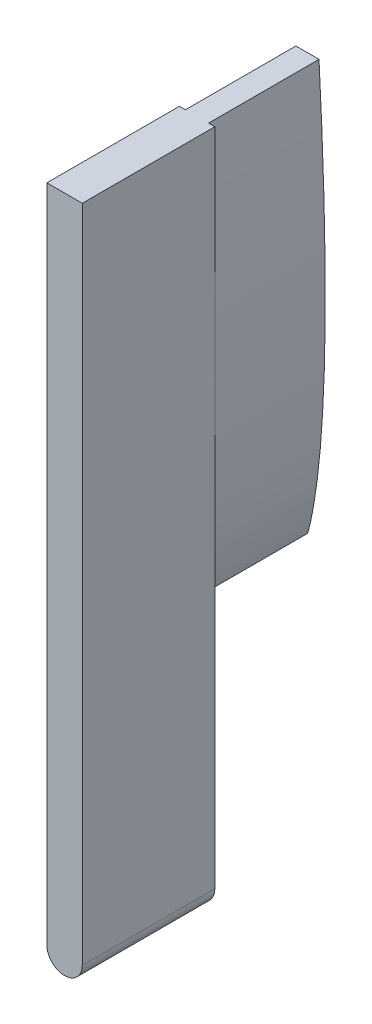
from build123d import *

# Parameters (mm, degrees)
BOSS_EXTRUDE1_DEPTH = 12
BOSS_EXTRUDE2_DEPTH = 10
SKETCH4_W           = 13.751659717
SKETCH4_H           = 46.366215506
CUT_EXTRUDE1_DEPTH  = 10
SKETCH5_W           = 8.283570047
SKETCH5_H           = 65.91855038
CUT_EXTRUDE2_DEPTH  = 12


with BuildPart() as part:
    # Sketch2 → Boss-Extrude1 (new body)
    with BuildSketch(Plane(origin=(0, 0, 24.631338753), x_dir=(-1, 0, 0), z_dir=(0, 0, -1))):
        with BuildLine():
            Line((1.823068058, 603), (1.823068058, 663))
            Line((1.823068058, 663), (-1.882857166, 663))
            Line((-1.882857166, 663), (-1.882857166, 603))
            ThreePointArc((-1.882857166, 603), (-0.029894554, 601.147037388), (1.823068058, 603))
        make_face()
    extrude(amount=-BOSS_EXTRUDE1_DEPTH)

    # Sketch3 → Boss-Extrude2 (add)
    with BuildSketch(Plane(origin=(0, 0, 24.631338753), x_dir=(-1, 0, 0), z_dir=(0, 0, -1))):
        with BuildLine():
            Line((1.264894076, 663), (-1.303734146, 663))
            add(Edge.make_bspline(
                [(-1.303734146, 663), (-1.370231135, 661.776635062), (-1.590250356, 657.449713113), (-1.807353062, 651.572171687), (-1.896585428, 645.372497792), (-1.86904968, 640.732879739), (-1.745534221, 636.874692995), (-1.562088565, 633.805492743), (-1.371788238, 631.514699269), (-1.110556109, 629.246267473), (-0.82006967, 627.376977333), (-0.524480825, 625.91989796), (-0.290142677, 624.999996337), (-0.11575841, 624.480032386), (-0.0414459, 624.290359908)],
                knots=[0.640306561, 0.640306561, 0.640306561, 0.640306561, 0.664641164, 0.726373771, 0.757240075, 0.788106379, 0.818972683, 0.834405835, 0.849838987, 0.865272139, 0.88070529, 0.888421866, 0.896138442, 0.901180622, 0.901180622, 0.901180622, 0.901180622], degree=3))
            add(Edge.make_bspline(
                [(-0.0414459, 624.290359908), (0.033082795, 624.479947544), (0.208059728, 624.999712352), (0.443446447, 625.919346223), (0.740696225, 627.376087666), (1.033313538, 629.245045426), (1.297131595, 631.513177934), (1.490043391, 633.803752969), (1.676987934, 636.872742091), (1.804901792, 640.730785516), (1.837726863, 645.370369162), (1.755562421, 651.570140757), (1.545143008, 657.448413886), (1.33002573, 661.776072077), (1.264894076, 663)],
                knots=[0.516530112, 0.516530112, 0.516530112, 0.516530112, 0.521572291, 0.529288867, 0.537005443, 0.552438595, 0.567871747, 0.583304899, 0.598738051, 0.629604354, 0.660470658, 0.691336962, 0.75306957, 0.777413882, 0.777413882, 0.777413882, 0.777413882], degree=3))
        make_face()
    extrude(amount=BOSS_EXTRUDE2_DEPTH)

    # Sketch4 → Cut-Extrude1 (cut)
    with BuildSketch(Plane(origin=(0, 0, 14.631338753), x_dir=(-1, 0, 0), z_dir=(0, 0, -1))):
        with Locations((-1.173878519, 643.806595501)):
            Rectangle(SKETCH4_W, SKETCH4_H)
        with BuildLine():
            Line((1.027790464, 662.75), (-1.066900471, 662.75))
            add(Edge.make_bspline(
                [(-1.066900471, 662.75), (-1.236503852, 659.603485126), (-1.378670819, 656.455796636), (-1.57969897, 650.156856184), (-1.640644161, 647.006539015), (-1.627793637, 642.280065577), (-1.605967013, 640.704411435), (-1.51576118, 637.5585905), (-1.447339544, 635.987803899), (-1.241955745, 632.852473359), (-1.105208785, 631.287909819), (-0.807374159, 628.949508907), (-0.693510346, 628.171370392), (-0.487056782, 627.00741033), (-0.412632368, 626.619934288), (-0.245133833, 625.846680816), (-0.152824444, 625.460833735), (-0.040997635, 625.076764299)],
                knots=[0, 0, 0, 0, 0.25, 0.25, 0.5, 0.5, 0.625, 0.625, 0.75, 0.75, 0.875, 0.875, 0.9375, 0.9375, 0.96875, 0.96875, 1, 1, 1, 1], degree=3))
            add(Edge.make_bspline(
                [(-0.040997635, 625.076764299), (0.070840901, 625.459248905), (0.163415052, 625.843948539), (0.33153675, 626.615305535), (0.406338832, 627.002048611), (0.614008944, 628.164202165), (0.728805435, 628.941690519), (1.029518166, 631.279177553), (1.168319449, 632.844593533), (1.37765883, 635.983274427), (1.448032565, 637.557347723), (1.541893042, 640.707003283), (1.565447656, 642.281912238), (1.583609245, 647.006821426), (1.526236009, 650.157618773), (1.332376457, 656.455957525), (1.193802364, 659.603511067), (1.027790464, 662.75)],
                knots=[0, 0, 0, 0, 0.03125, 0.03125, 0.0625, 0.0625, 0.125, 0.125, 0.25, 0.25, 0.375, 0.375, 0.5, 0.5, 0.75, 0.75, 1, 1, 1, 1], degree=3))
        make_face(mode=Mode.SUBTRACT)
    extrude(amount=-CUT_EXTRUDE1_DEPTH, mode=Mode.SUBTRACT)

    # Sketch5 → Cut-Extrude2 (cut)
    with BuildSketch(Plane.XY.offset(36.631338753)):
        with Locations((0.019038526, 632.037504846)):
            Rectangle(SKETCH5_W, SKETCH5_H)
        with BuildLine():
            Line((1.632857166, 603), (1.632857166, 662.75))
            Line((1.632857166, 662.75), (-1.573068058, 662.75))
            Line((-1.573068058, 662.75), (-1.573068058, 603))
            ThreePointArc((-1.573068058, 603), (0.029894554, 601.397037388), (1.632857166, 603))
        make_face(mode=Mode.SUBTRACT)
    extrude(amount=-CUT_EXTRUDE2_DEPTH, mode=Mode.SUBTRACT)


solid = part.part
